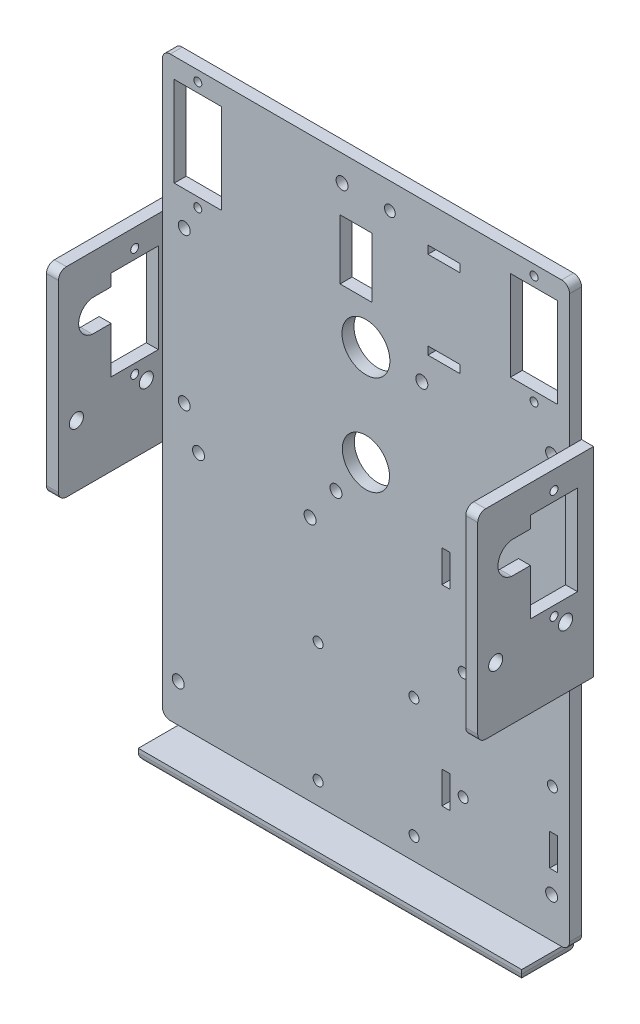
from build123d import *

# Parameters (mm, degrees)
MODEL_R                  = 1.5
MODEL_R_2                = 1
MODEL_R_3                = 6
MODEL_R_4                = 1.25
MODEL_R_5                = 1.349782665
MODEL_R_6                = 5.9
MODEL_W                  = 8
MODEL_H                  = 15
MODEL_H_2                = 2
MODEL_W_2                = 11.8
MODEL_H_3                = 22.5
MODEL_W_3                = 2
MODEL_H_4                = 8
MODEL_H_5                = 7.999999999
SALIENTE_EXTRUIR1_DEPTH  = 3
CROQUIS2_W               = 3
CROQUIS2_H               = 50
SALIENTE_EXTRUIR2_DEPTH  = 29
CROQUIS3_R               = 1.765481919
CROQUIS3_R_2             = 1
CORTAR_EXTRUIR1_DEPTH    = 3
REDONDEO1_R              = 2
REDONDEO1_OF_SIMETR_A1_R = 2
CROQUIS4_W               = 96
CROQUIS4_H               = 3
SALIENTE_EXTRUIR3_DEPTH  = 13
REDONDEO2_R              = 2


with BuildPart() as part:
    # Model → Saliente-Extruir1 (new body)
    with BuildSketch(Plane.XY):
        with BuildLine():
            Line((13.198959583, -198.58599061), (108.142640241, -198.58599061))
            Line((108.142640241, -198.58599061), (109.670799912, -198.585990609))
            ThreePointArc((109.670799912, -198.585990609), (111.085013474, -198.000204172), (111.670799912, -196.58599061))
            Line((111.670799912, -196.58599061), (111.670799912, -139.134723681))
            Line((111.670799912, -139.134723681), (114.670799912, -139.134723681))
            Line((114.670799912, -139.134723681), (114.670799912, -89.134723681))
            Line((114.670799912, -89.134723681), (111.670799912, -89.134723681))
            Line((111.670799912, -89.134723681), (111.670799912, -56.020997464))
            ThreePointArc((111.670799912, -56.020997464), (111.085013474, -54.606783901), (109.670799912, -54.020997464))
            Line((109.670799912, -54.020997464), (77.898959582, -54.020997464))
            Line((77.898959582, -54.020997464), (43.555278924, -54.020997464))
            Line((43.555278924, -54.020997464), (11.670799912, -54.020997464))
            ThreePointArc((11.670799912, -54.020997464), (10.256586349, -54.606783901), (9.670799912, -56.020997464))
            Line((9.670799912, -56.020997464), (9.670799912, -89.134723681))
            Line((9.670799912, -89.134723681), (6.670799912, -89.134723681))
            Line((6.670799912, -89.134723681), (6.670799912, -139.134723681))
            Line((6.670799912, -139.134723681), (9.670799912, -139.134723681))
            Line((9.670799912, -139.134723681), (9.670799912, -196.585990609))
            ThreePointArc((9.670799912, -196.585990609), (10.256586349, -198.000204172), (11.670799912, -198.585990609))
            Line((11.670799912, -198.585990609), (13.198959583, -198.58599061))
        make_face()
        with Locations((107.170799912, -93.113896801)):
            Circle(MODEL_R, mode=Mode.SUBTRACT)
        with Locations((102.770799912, -56.620997464)):
            Circle(MODEL_R_2, mode=Mode.SUBTRACT)
        with Locations((102.770799912, -83.920997464)):
            Circle(MODEL_R_2, mode=Mode.SUBTRACT)
        with Locations((18.570799912, -83.920997464)):
            Circle(MODEL_R_2, mode=Mode.SUBTRACT)
        with Locations((18.570799912, -56.620997464)):
            Circle(MODEL_R_2, mode=Mode.SUBTRACT)
        with Locations((60.670799912, -93.098913634)):
            Circle(MODEL_R_3, mode=Mode.SUBTRACT)
        with Locations((15.170799912, -90.015990609)):
            Circle(MODEL_R, mode=Mode.SUBTRACT)
        with Locations((46.690799912, -137.01599061)):
            Circle(MODEL_R, mode=Mode.SUBTRACT)
        with Locations((18.750799912, -137.01599061)):
            Circle(MODEL_R, mode=Mode.SUBTRACT)
        with Locations((13.670799912, -189.085990609)):
            Circle(MODEL_R, mode=Mode.SUBTRACT)
        with Locations((53.170799912, -128.015990609)):
            Circle(MODEL_R, mode=Mode.SUBTRACT)
        with Locations((15.170799912, -128.015990609)):
            Circle(MODEL_R, mode=Mode.SUBTRACT)
        with Locations((107.373959583, -165.015945956)):
            Circle(MODEL_R_4, mode=Mode.SUBTRACT)
        with Locations((85.023959582, -151.515945956)):
            Circle(MODEL_R_4, mode=Mode.SUBTRACT)
        with Locations((85.023959582, -178.515945956)):
            Circle(MODEL_R_4, mode=Mode.SUBTRACT)
        with Locations((66.670799912, -60.520997464)):
            Circle(MODEL_R_5, mode=Mode.SUBTRACT)
        with Locations((107.170799912, -188.585990609)):
            Circle(MODEL_R, mode=Mode.SUBTRACT)
        with Locations((74.670799912, -93.580727597)):
            Circle(MODEL_R, mode=Mode.SUBTRACT)
        with Locations((60.670799912, -118.098913634)):
            Circle(MODEL_R_6, mode=Mode.SUBTRACT)
        with Locations((54.698959583, -60.520997464)):
            Circle(MODEL_R, mode=Mode.SUBTRACT)
        with Locations((48.698959583, -193.085990609)):
            Circle(MODEL_R_4, mode=Mode.SUBTRACT)
        with Locations((72.727119253, -193.085990609)):
            Circle(MODEL_R_4, mode=Mode.SUBTRACT)
        with Locations((72.698959582, -163.085990609)):
            Circle(MODEL_R_4, mode=Mode.SUBTRACT)
        with Locations((48.698959583, -163.085990609)):
            Circle(MODEL_R_4, mode=Mode.SUBTRACT)
        with Locations((58.198959582, -75.127025732)):
            Rectangle(MODEL_W, MODEL_H, mode=Mode.SUBTRACT)
        with Locations((80.198959582, -64.186772947)):
            Rectangle(MODEL_W, MODEL_H_2, mode=Mode.SUBTRACT)
        with Locations((80.198959582, -86.067481229)):
            Rectangle(MODEL_W, MODEL_H_2, mode=Mode.SUBTRACT)
        with Locations((102.770799912, -70.270997464)):
            Rectangle(MODEL_W_2, MODEL_H_3, mode=Mode.SUBTRACT)
        with Locations((18.570799912, -70.270997464)):
            Rectangle(MODEL_W_2, MODEL_H_3, mode=Mode.SUBTRACT)
        with Locations((80.698959582, -179.08599061)):
            Rectangle(MODEL_W_3, MODEL_H_4, mode=Mode.SUBTRACT)
        with Locations((107.670799912, -179.08599061)):
            Rectangle(MODEL_W_3, MODEL_H_5, mode=Mode.SUBTRACT)
        with Locations((80.698959582, -131.08599061)):
            Rectangle(MODEL_W_3, MODEL_H_4, mode=Mode.SUBTRACT)
        with Locations((108.198959582, -132.085990609)):
            Rectangle(MODEL_W_3, MODEL_H_4, mode=Mode.SUBTRACT)
    extrude(amount=SALIENTE_EXTRUIR1_DEPTH)

    # Croquis2 → Saliente-Extruir2 (add)
    with BuildSketch(Plane(origin=(0, 0, 0), x_dir=(-1, 0, 0), z_dir=(0, 0, -1))):
        with Locations((-113.170799912, -114.134723681)):
            Rectangle(CROQUIS2_W, CROQUIS2_H)
    saliente_extruir2 = extrude(amount=-SALIENTE_EXTRUIR2_DEPTH)

    # Croquis3 → Cortar-Extruir1 (cut)
    with BuildSketch(Plane(origin=(114.670799912, 0, 0), x_dir=(0, 0, -1), z_dir=(1, 0, 0))):
        with Locations((-24.5, -123.734723681)):
            Circle(CROQUIS3_R)
        with Locations((-7, -123.734723681)):
            Circle(CROQUIS3_R)
        with Locations((-9.9, -121.034548102)):
            Circle(CROQUIS3_R_2)
        with Locations((-9.9, -93.734723681)):
            Circle(CROQUIS3_R_2)
        with BuildLine():
            Line((-4, -118.634723681), (-4, -96.134723681))
            Line((-4, -96.134723681), (-15.8, -96.134723681))
            Line((-15.8, -96.134723681), (-15.8, -99.134723681))
            Line((-15.8, -99.134723681), (-20.577507922, -99.134723681))
            ThreePointArc((-20.577507922, -99.134723681), (-23.938367399, -103.128314954), (-20.488619892, -107.045378882))
            Line((-20.488619892, -107.045378882), (-15.8, -107.045378882))
            Line((-15.8, -107.045378882), (-15.8, -118.634723681))
            Line((-15.8, -118.634723681), (-4, -118.634723681))
        make_face()
    cortar_extruir1 = extrude(amount=-CORTAR_EXTRUIR1_DEPTH, mode=Mode.SUBTRACT)

    # Redondeo1
    redondeo1_edges = [part.edges().sort_by_distance(p)[0] for p in [
        (113.170799912, -89.134723681, 29),
        (113.170799912, -139.134723681, 29),
    ]]
    fillet(redondeo1_edges, radius=REDONDEO1_R)

    # Simetría1: Saliente-Extruir2, Cortar-Extruir1 across plane
    add(saliente_extruir2.mirror(Plane(origin=(60.670799912, 0, 0), x_dir=(0, 0, 1), z_dir=(1, 0, 0))))
    add(cortar_extruir1.mirror(Plane(origin=(60.670799912, 0, 0), x_dir=(0, 0, 1), z_dir=(1, 0, 0))), mode=Mode.SUBTRACT)

    # Redondeo1 of Simetría1
    redondeo1_of_simetr_a1_edges = [part.edges().sort_by_distance(p)[0] for p in [
        (8.170799912, -89.134723681, 29),
        (8.170799912, -139.134723681, 29),
    ]]
    fillet(redondeo1_of_simetr_a1_edges, radius=REDONDEO1_OF_SIMETR_A1_R)

    # Croquis4 → Saliente-Extruir3 (add)
    with BuildSketch(Plane(origin=(0, 0, 0), x_dir=(-1, 0, 0), z_dir=(0, 0, -1))):
        with Locations((-61.670799912, -200.085990609)):
            Rectangle(CROQUIS4_W, CROQUIS4_H)
    extrude(amount=-SALIENTE_EXTRUIR3_DEPTH)

    # Redondeo2
    redondeo2_edges = [part.edges().sort_by_distance(p)[0] for p in [
        (61.670799912, -201.585990609, 13),
        (13.670799912, -201.585990609, 6.5),
        (109.670799912, -201.585990609, 6.5),
        (61.670799912, -201.585990609, 0),
    ]]
    fillet(redondeo2_edges, radius=REDONDEO2_R)


solid = part.part
